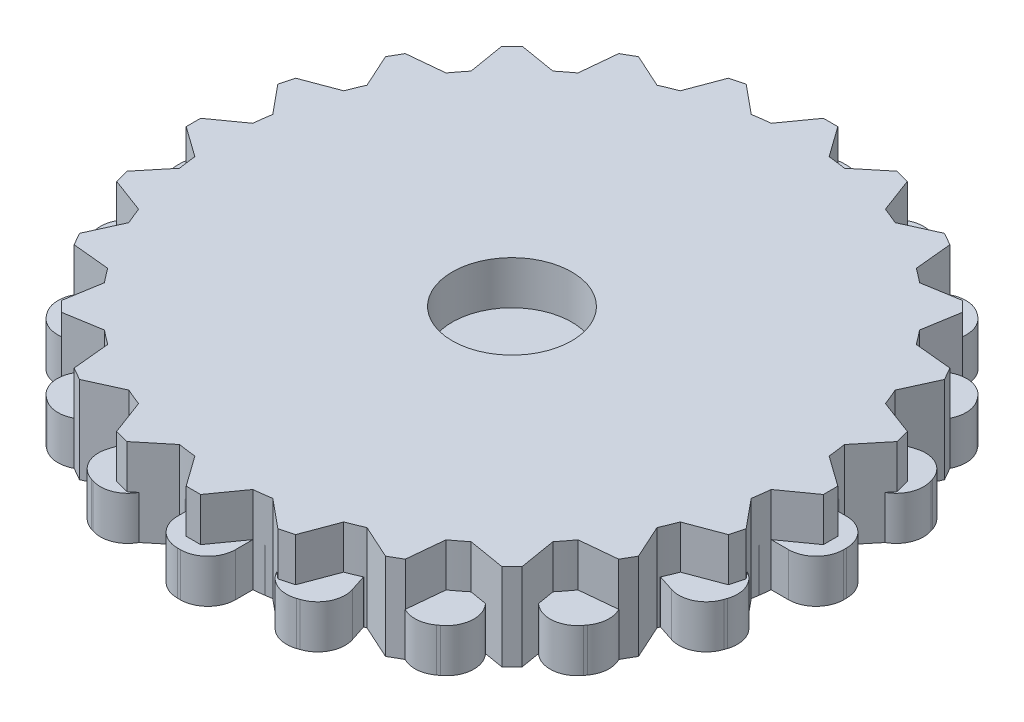
from build123d import *

# Parameters (mm, degrees)
BOSS_EXTRUDE3_DEPTH = 3
BOSS_EXTRUDE5_DEPTH = 6
BOSS_EXTRUDE6_DEPTH = 3
SKETCH4_R           = 4.125
CUT_EXTRUDE1_DEPTH  = 10


with BuildPart() as part:
    # Sketch2 → Boss-Extrude3 (new body)
    with BuildSketch(Plane(origin=(0, 0, 0), x_dir=(1, 0, 0), z_dir=(0, 1, 0))):
        with BuildLine():
            Line((-23, -0.1), (-23, 0.1))
            ThreePointArc((-23, 0.1), (-22.443502884, 1.443502884), (-21.1, 2))
            Line((-21.1, 2), (-19.899748742, 2))
            ThreePointArc((-19.899748742, 2), (-19.753766812, 3.128689301), (-19.543819703, 4.247247513))
            Line((-19.543819703, 4.247247513), (-20.685326483, 4.618145549))
            ThreePointArc((-20.685326483, 4.618145549), (-21.791106589, 5.56257098), (-21.905201574, 7.012285219))
            Line((-21.905201574, 7.012285219), (-21.843398175, 7.202496522))
            ThreePointArc((-21.843398175, 7.202496522), (-20.898972744, 8.308276629), (-19.449258505, 8.422371614))
            Line((-19.449258505, 8.422371614), (-18.307751725, 8.051473578))
            ThreePointArc((-18.307751725, 8.051473578), (-17.820130484, 9.079809995), (-17.274805421, 10.078744846))
            Line((-17.274805421, 10.078744846), (-18.245829086, 10.784234835))
            ThreePointArc((-18.245829086, 10.784234835), (-19.005644954, 12.02414164), (-18.666169396, 13.438159103))
            Line((-18.666169396, 13.438159103), (-18.548612345, 13.599962502))
            ThreePointArc((-18.548612345, 13.599962502), (-17.30870554, 14.35977837), (-15.894688077, 14.020302812))
            Line((-15.894688077, 14.020302812), (-14.923664412, 13.314812824))
            ThreePointArc((-14.923664412, 13.314812824), (-14.142135624, 14.142135624), (-13.314812824, 14.923664412))
            Line((-13.314812824, 14.923664412), (-14.020302812, 15.894688077))
            ThreePointArc((-14.020302812, 15.894688077), (-14.35977837, 17.30870554), (-13.599962502, 18.548612345))
            Line((-13.599962502, 18.548612345), (-13.438159103, 18.666169396))
            ThreePointArc((-13.438159103, 18.666169396), (-12.02414164, 19.005644954), (-10.784234835, 18.245829086))
            Line((-10.784234835, 18.245829086), (-10.078744846, 17.274805421))
            ThreePointArc((-10.078744846, 17.274805421), (-9.079809995, 17.820130484), (-8.051473578, 18.307751725))
            Line((-8.051473578, 18.307751725), (-8.422371614, 19.449258505))
            ThreePointArc((-8.422371614, 19.449258505), (-8.308276629, 20.898972744), (-7.202496522, 21.843398175))
            Line((-7.202496522, 21.843398175), (-7.012285219, 21.905201574))
            ThreePointArc((-7.012285219, 21.905201574), (-5.56257098, 21.791106589), (-4.618145549, 20.685326483))
            Line((-4.618145549, 20.685326483), (-4.247247513, 19.543819703))
            ThreePointArc((-4.247247513, 19.543819703), (-3.128689301, 19.753766812), (-2, 19.899748742))
            Line((-2, 19.899748742), (-2, 21.1))
            ThreePointArc((-2, 21.1), (-1.443502884, 22.443502884), (-0.1, 23))
            Line((-0.1, 23), (0.1, 23))
            ThreePointArc((0.1, 23), (1.443502884, 22.443502884), (2, 21.1))
            Line((2, 21.1), (2, 19.899748742))
            ThreePointArc((2, 19.899748742), (3.128689301, 19.753766812), (4.247247513, 19.543819703))
            Line((4.247247513, 19.543819703), (4.618145549, 20.685326483))
            ThreePointArc((4.618145549, 20.685326483), (5.56257098, 21.791106589), (7.012285219, 21.905201574))
            Line((7.012285219, 21.905201574), (7.202496522, 21.843398175))
            ThreePointArc((7.202496522, 21.843398175), (8.308276629, 20.898972744), (8.422371614, 19.449258505))
            Line((8.422371614, 19.449258505), (8.051473578, 18.307751725))
            ThreePointArc((8.051473578, 18.307751725), (9.079809995, 17.820130484), (10.078744846, 17.274805421))
            Line((10.078744846, 17.274805421), (10.784234835, 18.245829086))
            ThreePointArc((10.784234835, 18.245829086), (12.02414164, 19.005644954), (13.438159103, 18.666169396))
            Line((13.438159103, 18.666169396), (13.599962502, 18.548612345))
            ThreePointArc((13.599962502, 18.548612345), (14.35977837, 17.30870554), (14.020302812, 15.894688077))
            Line((14.020302812, 15.894688077), (13.314812824, 14.923664412))
            ThreePointArc((13.314812824, 14.923664412), (14.142135624, 14.142135624), (14.923664412, 13.314812824))
            Line((14.923664412, 13.314812824), (15.894688077, 14.020302812))
            ThreePointArc((15.894688077, 14.020302812), (17.30870554, 14.35977837), (18.548612345, 13.599962502))
            Line((18.548612345, 13.599962502), (18.666169396, 13.438159103))
            ThreePointArc((18.666169396, 13.438159103), (19.005644954, 12.02414164), (18.245829086, 10.784234835))
            Line((18.245829086, 10.784234835), (17.274805421, 10.078744846))
            ThreePointArc((17.274805421, 10.078744846), (17.820130484, 9.079809995), (18.307751725, 8.051473578))
            Line((18.307751725, 8.051473578), (19.449258505, 8.422371614))
            ThreePointArc((19.449258505, 8.422371614), (20.898972744, 8.308276629), (21.843398175, 7.202496522))
            Line((21.843398175, 7.202496522), (21.905201574, 7.012285219))
            ThreePointArc((21.905201574, 7.012285219), (21.791106589, 5.56257098), (20.685326483, 4.618145549))
            Line((20.685326483, 4.618145549), (19.543819703, 4.247247513))
            ThreePointArc((19.543819703, 4.247247513), (19.753766812, 3.128689301), (19.899748742, 2))
            Line((19.899748742, 2), (21.1, 2))
            ThreePointArc((21.1, 2), (22.443502884, 1.443502884), (23, 0.1))
            Line((23, 0.1), (23, -0.1))
            ThreePointArc((23, -0.1), (22.443502884, -1.443502884), (21.1, -2))
            Line((21.1, -2), (19.899748742, -2))
            ThreePointArc((19.899748742, -2), (19.753766812, -3.128689301), (19.543819703, -4.247247513))
            Line((19.543819703, -4.247247513), (20.685326483, -4.618145549))
            ThreePointArc((20.685326483, -4.618145549), (21.791106589, -5.56257098), (21.905201574, -7.012285219))
            Line((21.905201574, -7.012285219), (21.843398175, -7.202496522))
            ThreePointArc((21.843398175, -7.202496522), (20.898972744, -8.308276629), (19.449258505, -8.422371614))
            Line((19.449258505, -8.422371614), (18.307751725, -8.051473578))
            ThreePointArc((18.307751725, -8.051473578), (17.820130484, -9.079809995), (17.274805421, -10.078744846))
            Line((17.274805421, -10.078744846), (18.245829086, -10.784234835))
            ThreePointArc((18.245829086, -10.784234835), (19.005644954, -12.02414164), (18.666169396, -13.438159103))
            Line((18.666169396, -13.438159103), (18.548612345, -13.599962502))
            ThreePointArc((18.548612345, -13.599962502), (17.30870554, -14.35977837), (15.894688077, -14.020302812))
            Line((15.894688077, -14.020302812), (14.923664412, -13.314812824))
            ThreePointArc((14.923664412, -13.314812824), (14.142135624, -14.142135624), (13.314812824, -14.923664412))
            Line((13.314812824, -14.923664412), (14.020302812, -15.894688077))
            ThreePointArc((14.020302812, -15.894688077), (14.35977837, -17.30870554), (13.599962502, -18.548612345))
            Line((13.599962502, -18.548612345), (13.438159103, -18.666169396))
            ThreePointArc((13.438159103, -18.666169396), (12.02414164, -19.005644954), (10.784234835, -18.245829086))
            Line((10.784234835, -18.245829086), (10.078744846, -17.274805421))
            ThreePointArc((10.078744846, -17.274805421), (9.079809995, -17.820130484), (8.051473578, -18.307751725))
            Line((8.051473578, -18.307751725), (8.422371614, -19.449258505))
            ThreePointArc((8.422371614, -19.449258505), (8.308276629, -20.898972744), (7.202496522, -21.843398175))
            Line((7.202496522, -21.843398175), (7.012285219, -21.905201574))
            ThreePointArc((7.012285219, -21.905201574), (5.56257098, -21.791106589), (4.618145549, -20.685326483))
            Line((4.618145549, -20.685326483), (4.247247513, -19.543819703))
            ThreePointArc((4.247247513, -19.543819703), (3.128689301, -19.753766812), (2, -19.899748742))
            Line((2, -19.899748742), (2, -21.1))
            ThreePointArc((2, -21.1), (1.443502884, -22.443502884), (0.1, -23))
            Line((0.1, -23), (-0.1, -23))
            ThreePointArc((-0.1, -23), (-1.443502884, -22.443502884), (-2, -21.1))
            Line((-2, -21.1), (-2, -19.899748742))
            ThreePointArc((-2, -19.899748742), (-3.128689301, -19.753766812), (-4.247247513, -19.543819703))
            Line((-4.247247513, -19.543819703), (-4.618145549, -20.685326483))
            ThreePointArc((-4.618145549, -20.685326483), (-5.56257098, -21.791106589), (-7.012285219, -21.905201574))
            Line((-7.012285219, -21.905201574), (-7.202496522, -21.843398175))
            ThreePointArc((-7.202496522, -21.843398175), (-8.308276629, -20.898972744), (-8.422371614, -19.449258505))
            Line((-8.422371614, -19.449258505), (-8.051473578, -18.307751725))
            ThreePointArc((-8.051473578, -18.307751725), (-9.079809995, -17.820130484), (-10.078744846, -17.274805421))
            Line((-10.078744846, -17.274805421), (-10.784234835, -18.245829086))
            ThreePointArc((-10.784234835, -18.245829086), (-12.02414164, -19.005644954), (-13.438159103, -18.666169396))
            Line((-13.438159103, -18.666169396), (-13.599962502, -18.548612345))
            ThreePointArc((-13.599962502, -18.548612345), (-14.35977837, -17.30870554), (-14.020302812, -15.894688077))
            Line((-14.020302812, -15.894688077), (-13.314812824, -14.923664412))
            ThreePointArc((-13.314812824, -14.923664412), (-14.142135624, -14.142135624), (-14.923664412, -13.314812824))
            Line((-14.923664412, -13.314812824), (-15.894688077, -14.020302812))
            ThreePointArc((-15.894688077, -14.020302812), (-17.30870554, -14.35977837), (-18.548612345, -13.599962502))
            Line((-18.548612345, -13.599962502), (-18.666169396, -13.438159103))
            ThreePointArc((-18.666169396, -13.438159103), (-19.005644954, -12.02414164), (-18.245829086, -10.784234835))
            Line((-18.245829086, -10.784234835), (-17.274805421, -10.078744846))
            ThreePointArc((-17.274805421, -10.078744846), (-17.820130484, -9.079809995), (-18.307751725, -8.051473578))
            Line((-18.307751725, -8.051473578), (-19.449258505, -8.422371614))
            ThreePointArc((-19.449258505, -8.422371614), (-20.898972744, -8.308276629), (-21.843398175, -7.202496522))
            Line((-21.843398175, -7.202496522), (-21.905201574, -7.012285219))
            ThreePointArc((-21.905201574, -7.012285219), (-21.791106589, -5.56257098), (-20.685326483, -4.618145549))
            Line((-20.685326483, -4.618145549), (-19.543819703, -4.247247513))
            ThreePointArc((-19.543819703, -4.247247513), (-19.753766812, -3.128689301), (-19.899748742, -2))
            Line((-19.899748742, -2), (-21.1, -2))
            ThreePointArc((-21.1, -2), (-22.443502884, -1.443502884), (-23, -0.1))
        make_face()
    extrude(amount=BOSS_EXTRUDE3_DEPTH)


with BuildPart() as body_2:
    # Sketch3 → Boss-Extrude5 (new body)
    with BuildSketch(Plane(origin=(0, 0, 0), x_dir=(1, 0, 0), z_dir=(0, 1, 0))):
        with BuildLine():
            Line((-22, 0.5), (-22, 0))
            Line((-22, 0), (22, 0))
            Line((22, 0), (22, 0.5))
            Line((22, 0.5), (19.899748742, 2))
            ThreePointArc((19.899748742, 2), (19.828897227, 2.610523844), (19.739319337, 3.218582315))
            Line((19.739319337, 3.218582315), (21.379777701, 5.211056079))
            Line((21.379777701, 5.211056079), (21.120958656, 6.176981905))
            Line((21.120958656, 6.176981905), (18.704043156, 7.08228562))
            ThreePointArc((18.704043156, 7.08228562), (18.47759065, 7.653668647), (18.23368794, 8.217823563))
            Line((18.23368794, 8.217823563), (19.302558883, 10.566987298))
            Line((19.302558883, 10.566987298), (18.802558883, 11.433012702))
            Line((18.802558883, 11.433012702), (16.23368794, 11.681925179))
            ThreePointArc((16.23368794, 11.681925179), (15.867066806, 12.17522858), (15.485460842, 12.657033717))
            Line((15.485460842, 12.657033717), (15.909902577, 15.202795796))
            Line((15.909902577, 15.202795796), (15.202795796, 15.909902577))
            Line((15.202795796, 15.909902577), (12.657033717, 15.485460842))
            ThreePointArc((12.657033717, 15.485460842), (12.17522858, 15.867066806), (11.681925179, 16.23368794))
            Line((11.681925179, 16.23368794), (11.433012702, 18.802558883))
            Line((11.433012702, 18.802558883), (10.566987298, 19.302558883))
            Line((10.566987298, 19.302558883), (8.217823563, 18.23368794))
            ThreePointArc((8.217823563, 18.23368794), (7.653668647, 18.47759065), (7.08228562, 18.704043156))
            Line((7.08228562, 18.704043156), (6.176981905, 21.120958656))
            Line((6.176981905, 21.120958656), (5.211056079, 21.379777701))
            Line((5.211056079, 21.379777701), (3.218582315, 19.739319337))
            ThreePointArc((3.218582315, 19.739319337), (2.610523844, 19.828897227), (2, 19.899748742))
            Line((2, 19.899748742), (0.5, 22))
            Line((0.5, 22), (-0.5, 22))
            Line((-0.5, 22), (-2, 19.899748742))
            ThreePointArc((-2, 19.899748742), (-2.610523844, 19.828897227), (-3.218582315, 19.739319337))
            Line((-3.218582315, 19.739319337), (-5.211056079, 21.379777701))
            Line((-5.211056079, 21.379777701), (-6.176981905, 21.120958656))
            Line((-6.176981905, 21.120958656), (-7.08228562, 18.704043156))
            ThreePointArc((-7.08228562, 18.704043156), (-7.653668647, 18.47759065), (-8.217823563, 18.23368794))
            Line((-8.217823563, 18.23368794), (-10.566987298, 19.302558883))
            Line((-10.566987298, 19.302558883), (-11.433012702, 18.802558883))
            Line((-11.433012702, 18.802558883), (-11.681925179, 16.23368794))
            ThreePointArc((-11.681925179, 16.23368794), (-12.17522858, 15.867066806), (-12.657033717, 15.485460842))
            Line((-12.657033717, 15.485460842), (-15.202795796, 15.909902577))
            Line((-15.202795796, 15.909902577), (-15.909902577, 15.202795796))
            Line((-15.909902577, 15.202795796), (-15.485460842, 12.657033717))
            ThreePointArc((-15.485460842, 12.657033717), (-15.867066806, 12.17522858), (-16.23368794, 11.681925179))
            Line((-16.23368794, 11.681925179), (-18.802558883, 11.433012702))
            Line((-18.802558883, 11.433012702), (-19.302558883, 10.566987298))
            Line((-19.302558883, 10.566987298), (-18.23368794, 8.217823563))
            ThreePointArc((-18.23368794, 8.217823563), (-18.47759065, 7.653668647), (-18.704043156, 7.08228562))
            Line((-18.704043156, 7.08228562), (-21.120958656, 6.176981905))
            Line((-21.120958656, 6.176981905), (-21.379777701, 5.211056079))
            Line((-21.379777701, 5.211056079), (-19.739319337, 3.218582315))
            ThreePointArc((-19.739319337, 3.218582315), (-19.828897227, 2.610523844), (-19.899748742, 2))
            Line((-19.899748742, 2), (-22, 0.5))
        make_face()
        with BuildLine():
            Line((22, 0), (-22, 0))
            Line((-22, 0), (-22, -0.5))
            Line((-22, -0.5), (-19.899748742, -2))
            ThreePointArc((-19.899748742, -2), (-19.828897227, -2.610523844), (-19.739319337, -3.218582315))
            Line((-19.739319337, -3.218582315), (-21.379777701, -5.211056079))
            Line((-21.379777701, -5.211056079), (-21.120958656, -6.176981905))
            Line((-21.120958656, -6.176981905), (-18.704043156, -7.08228562))
            ThreePointArc((-18.704043156, -7.08228562), (-18.47759065, -7.653668647), (-18.23368794, -8.217823563))
            Line((-18.23368794, -8.217823563), (-19.302558883, -10.566987298))
            Line((-19.302558883, -10.566987298), (-18.802558883, -11.433012702))
            Line((-18.802558883, -11.433012702), (-16.23368794, -11.681925179))
            ThreePointArc((-16.23368794, -11.681925179), (-15.867066806, -12.17522858), (-15.485460842, -12.657033717))
            Line((-15.485460842, -12.657033717), (-15.909902577, -15.202795796))
            Line((-15.909902577, -15.202795796), (-15.202795796, -15.909902577))
            Line((-15.202795796, -15.909902577), (-12.657033717, -15.485460842))
            ThreePointArc((-12.657033717, -15.485460842), (-12.17522858, -15.867066806), (-11.681925179, -16.23368794))
            Line((-11.681925179, -16.23368794), (-11.433012702, -18.802558883))
            Line((-11.433012702, -18.802558883), (-10.566987298, -19.302558883))
            Line((-10.566987298, -19.302558883), (-8.217823563, -18.23368794))
            ThreePointArc((-8.217823563, -18.23368794), (-7.653668647, -18.47759065), (-7.08228562, -18.704043156))
            Line((-7.08228562, -18.704043156), (-6.176981905, -21.120958656))
            Line((-6.176981905, -21.120958656), (-5.211056079, -21.379777701))
            Line((-5.211056079, -21.379777701), (-3.218582315, -19.739319337))
            ThreePointArc((-3.218582315, -19.739319337), (-2.610523844, -19.828897227), (-2, -19.899748742))
            Line((-2, -19.899748742), (-0.5, -22))
            Line((-0.5, -22), (0.5, -22))
            Line((0.5, -22), (2, -19.899748742))
            ThreePointArc((2, -19.899748742), (2.610523844, -19.828897227), (3.218582315, -19.739319337))
            Line((3.218582315, -19.739319337), (5.211056079, -21.379777701))
            Line((5.211056079, -21.379777701), (6.176981905, -21.120958656))
            Line((6.176981905, -21.120958656), (7.08228562, -18.704043156))
            ThreePointArc((7.08228562, -18.704043156), (7.653668647, -18.47759065), (8.217823563, -18.23368794))
            Line((8.217823563, -18.23368794), (10.566987298, -19.302558883))
            Line((10.566987298, -19.302558883), (11.433012702, -18.802558883))
            Line((11.433012702, -18.802558883), (11.681925179, -16.23368794))
            ThreePointArc((11.681925179, -16.23368794), (12.17522858, -15.867066806), (12.657033717, -15.485460842))
            Line((12.657033717, -15.485460842), (15.202795796, -15.909902577))
            Line((15.202795796, -15.909902577), (15.909902577, -15.202795796))
            Line((15.909902577, -15.202795796), (15.485460842, -12.657033717))
            ThreePointArc((15.485460842, -12.657033717), (15.867066806, -12.17522858), (16.23368794, -11.681925179))
            Line((16.23368794, -11.681925179), (18.802558883, -11.433012702))
            Line((18.802558883, -11.433012702), (19.302558883, -10.566987298))
            Line((19.302558883, -10.566987298), (18.23368794, -8.217823563))
            ThreePointArc((18.23368794, -8.217823563), (18.47759065, -7.653668647), (18.704043156, -7.08228562))
            Line((18.704043156, -7.08228562), (21.120958656, -6.176981905))
            Line((21.120958656, -6.176981905), (21.379777701, -5.211056079))
            Line((21.379777701, -5.211056079), (19.739319337, -3.218582315))
            ThreePointArc((19.739319337, -3.218582315), (19.828897227, -2.610523844), (19.899748742, -2))
            Line((19.899748742, -2), (22, -0.5))
            Line((22, -0.5), (22, 0))
        make_face()
    extrude(amount=BOSS_EXTRUDE5_DEPTH)

    # Sketch4 → Cut-Extrude1 (cut)
    with BuildSketch(Plane(origin=(0, 6, 0), x_dir=(1, 0, 0), z_dir=(0, 1, 0))):
        Circle(SKETCH4_R)
    extrude(amount=-CUT_EXTRUDE1_DEPTH, mode=Mode.SUBTRACT)


with BuildPart() as body_3:
    # Sketch1 → Boss-Extrude6 (new body)
    with BuildSketch(Plane(origin=(0, 0, 0), x_dir=(1, 0, 0), z_dir=(0, 1, 0))):
        with BuildLine():
            Line((-0.5, 14.746169466), (0.5, 14.746169466))
            Line((0.5, 14.746169466), (2, 12.544128437))
            ThreePointArc((2, 12.544128437), (2.588190451, 12.405427729), (3.166928678, 12.23145084))
            Line((3.166928678, 12.23145084), (5.566987298, 13.388474311))
            Line((5.566987298, 13.388474311), (6.433012702, 12.888474311))
            Line((6.433012702, 12.888474311), (6.631030293, 10.23145084))
            ThreePointArc((6.631030293, 10.23145084), (7.071067812, 9.817237278), (7.485281374, 9.377199759))
            Line((7.485281374, 9.377199759), (10.142304845, 9.179182168))
            Line((10.142304845, 9.179182168), (10.642304845, 8.313156764))
            Line((10.642304845, 8.313156764), (9.485281374, 5.913098144))
            ThreePointArc((9.485281374, 5.913098144), (9.659258263, 5.334359917), (9.797958971, 4.746169466))
            Line((9.797958971, 4.746169466), (12, 3.246169466))
            Line((12, 3.246169466), (12, 2.246169466))
            Line((12, 2.246169466), (9.797958971, 0.746169466))
            ThreePointArc((9.797958971, 0.746169466), (9.659258263, 0.157979015), (9.485281374, -0.420759212))
            Line((9.485281374, -0.420759212), (10.642304845, -2.820817832))
            Line((10.642304845, -2.820817832), (10.142304845, -3.686843236))
            Line((10.142304845, -3.686843236), (7.485281374, -3.884860827))
            ThreePointArc((7.485281374, -3.884860827), (7.071067812, -4.324898346), (6.631030293, -4.739111908))
            Line((6.631030293, -4.739111908), (6.433012702, -7.39613538))
            Line((6.433012702, -7.39613538), (5.566987298, -7.89613538))
            Line((5.566987298, -7.89613538), (3.166928678, -6.739111908))
            ThreePointArc((3.166928678, -6.739111908), (2.588190451, -6.913088797), (2, -7.051789505))
            Line((2, -7.051789505), (0.5, -9.253830534))
            Line((0.5, -9.253830534), (-0.5, -9.253830534))
            Line((-0.5, -9.253830534), (-2, -7.051789505))
            ThreePointArc((-2, -7.051789505), (-2.588190451, -6.913088797), (-3.166928678, -6.739111908))
            Line((-3.166928678, -6.739111908), (-5.566987298, -7.89613538))
            Line((-5.566987298, -7.89613538), (-6.433012702, -7.39613538))
            Line((-6.433012702, -7.39613538), (-6.631030293, -4.739111908))
            ThreePointArc((-6.631030293, -4.739111908), (-7.071067812, -4.324898346), (-7.485281374, -3.884860827))
            Line((-7.485281374, -3.884860827), (-10.142304845, -3.686843236))
            Line((-10.142304845, -3.686843236), (-10.642304845, -2.820817832))
            Line((-10.642304845, -2.820817832), (-9.485281374, -0.420759212))
            ThreePointArc((-9.485281374, -0.420759212), (-9.659258263, 0.157979015), (-9.797958971, 0.746169466))
            Line((-9.797958971, 0.746169466), (-12, 2.246169466))
            Line((-12, 2.246169466), (-12, 3.246169466))
            Line((-12, 3.246169466), (-9.797958971, 4.746169466))
            ThreePointArc((-9.797958971, 4.746169466), (-9.659258263, 5.334359917), (-9.485281374, 5.913098144))
            Line((-9.485281374, 5.913098144), (-10.642304845, 8.313156764))
            Line((-10.642304845, 8.313156764), (-10.142304845, 9.179182168))
            Line((-10.142304845, 9.179182168), (-7.485281374, 9.377199759))
            ThreePointArc((-7.485281374, 9.377199759), (-7.071067812, 9.817237278), (-6.631030293, 10.23145084))
            Line((-6.631030293, 10.23145084), (-6.433012702, 12.888474311))
            Line((-6.433012702, 12.888474311), (-5.566987298, 13.388474311))
            Line((-5.566987298, 13.388474311), (-3.166928678, 12.23145084))
            ThreePointArc((-3.166928678, 12.23145084), (-2.588190451, 12.405427729), (-2, 12.544128437))
            Line((-2, 12.544128437), (-0.5, 14.746169466))
        make_face()
    extrude(amount=BOSS_EXTRUDE6_DEPTH)


solid = Compound([part.part, body_2.part, body_3.part])
